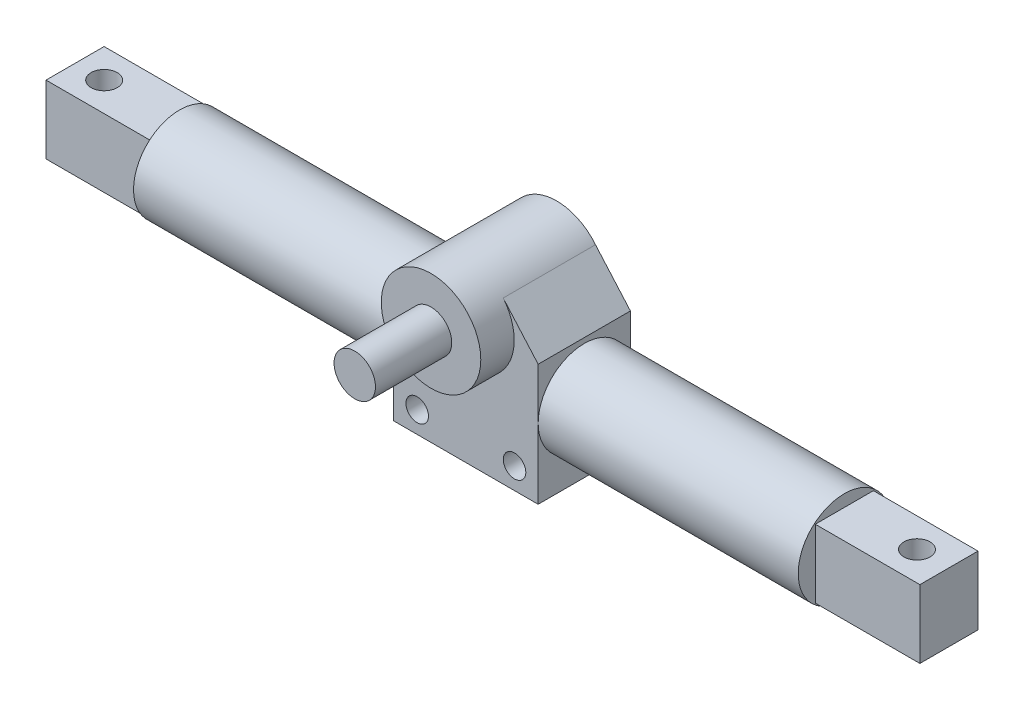
from build123d import *

# Parameters (mm, degrees)
SKETCH1_W           = 50.546
SKETCH1_H           = 42.418
BOSS_EXTRUDE1_DEPTH = 32.258
BOSS_EXTRUDE2_DEPTH = 32.258
SKETCH3_R           = 16.129
BOSS_EXTRUDE3_DEPTH = 90.932
SKETCH5_R           = 16.129
BOSS_EXTRUDE4_DEPTH = 90.932
SKETCH6_R           = 3.937
CUT_EXTRUDE1_DEPTH  = 90.932
SKETCH8_R           = 17.399
BOSS_EXTRUDE5_DEPTH = 11.684
SKETCH9_R           = 7.239
BOSS_EXTRUDE6_DEPTH = 26.67
SKETCH10_W          = 20.32
SKETCH10_H          = 23.876
BOSS_EXTRUDE7_DEPTH = 36.576
SKETCH11_W          = 20.32
SKETCH11_H          = 23.876
BOSS_EXTRUDE8_DEPTH = 36.576
SKETCH12_R          = 4.572
CUT_EXTRUDE2_DEPTH  = 36.576


with BuildPart() as part:
    # Sketch1 → Boss-Extrude1 (new body)
    with BuildSketch(Plane.XY):
        with Locations((25.273, 21.209)):
            Rectangle(SKETCH1_W, SKETCH1_H)
    extrude(amount=BOSS_EXTRUDE1_DEPTH)

    # Sketch2 → Boss-Extrude2 (add)
    with BuildSketch(Plane.XY.offset(32.258)):
        with BuildLine():
            Line((0, 42.418), (11.216038208, 56.368169759))
            ThreePointArc((11.216038208, 56.368169759), (24.775827865, 62.865), (38.335617522, 56.368169759))
            Line((38.335617522, 56.368169759), (50.546, 42.418))
            Line((50.546, 42.418), (0, 42.418))
        make_face()
    extrude(amount=-BOSS_EXTRUDE2_DEPTH)

    # Sketch3 → Boss-Extrude3 (add)
    with BuildSketch(Plane.ZY):
        with Locations((16.129, 24.511)):
            Circle(SKETCH3_R)
    extrude(amount=BOSS_EXTRUDE3_DEPTH)

    # Sketch5 → Boss-Extrude4 (add)
    with BuildSketch(Plane(origin=(50.546, 0, 0), x_dir=(0, 0, -1), z_dir=(1, 0, 0))):
        with Locations((-16.129, 24.511)):
            Circle(SKETCH5_R)
    extrude(amount=BOSS_EXTRUDE4_DEPTH)

    # Sketch6 → Cut-Extrude1 (cut)
    with BuildSketch(Plane.XY.offset(32.258)):
        with Locations((42.291, 7.493)):
            Circle(SKETCH6_R)
        with Locations((8.255, 7.493)):
            Circle(SKETCH6_R)
    extrude(amount=-CUT_EXTRUDE1_DEPTH, mode=Mode.SUBTRACT)

    # Sketch8 → Boss-Extrude5 (add)
    with BuildSketch(Plane.XY.offset(32.258)):
        with Locations((24.775827865, 45.466)):
            Circle(SKETCH8_R)
    extrude(amount=BOSS_EXTRUDE5_DEPTH)

    # Sketch9 → Boss-Extrude6 (add)
    with BuildSketch(Plane.XY.offset(43.942)):
        with Locations((24.775827865, 45.466)):
            Circle(SKETCH9_R)
    extrude(amount=BOSS_EXTRUDE6_DEPTH)

    # Sketch10 → Boss-Extrude7 (add)
    with BuildSketch(Plane(origin=(141.478, 0, 0), x_dir=(0, 0, -1), z_dir=(1, 0, 0))):
        with Locations((-16.129, 24.511)):
            Rectangle(SKETCH10_W, SKETCH10_H)
    extrude(amount=BOSS_EXTRUDE7_DEPTH)

    # Sketch11 → Boss-Extrude8 (add)
    with BuildSketch(Plane.ZY.offset(90.932)):
        with Locations((16.129, 24.511)):
            Rectangle(SKETCH11_W, SKETCH11_H)
    extrude(amount=BOSS_EXTRUDE8_DEPTH)

    # Sketch12 → Cut-Extrude2 (cut)
    with BuildSketch(Plane(origin=(0, 36.449, 0), x_dir=(1, 0, 0), z_dir=(0, 1, 0))):
        with Locations((166.878, -16.129)):
            Circle(SKETCH12_R)
        with Locations((-117.326344271, -16.129)):
            Circle(SKETCH12_R)
    extrude(amount=-CUT_EXTRUDE2_DEPTH, mode=Mode.SUBTRACT)


solid = part.part
